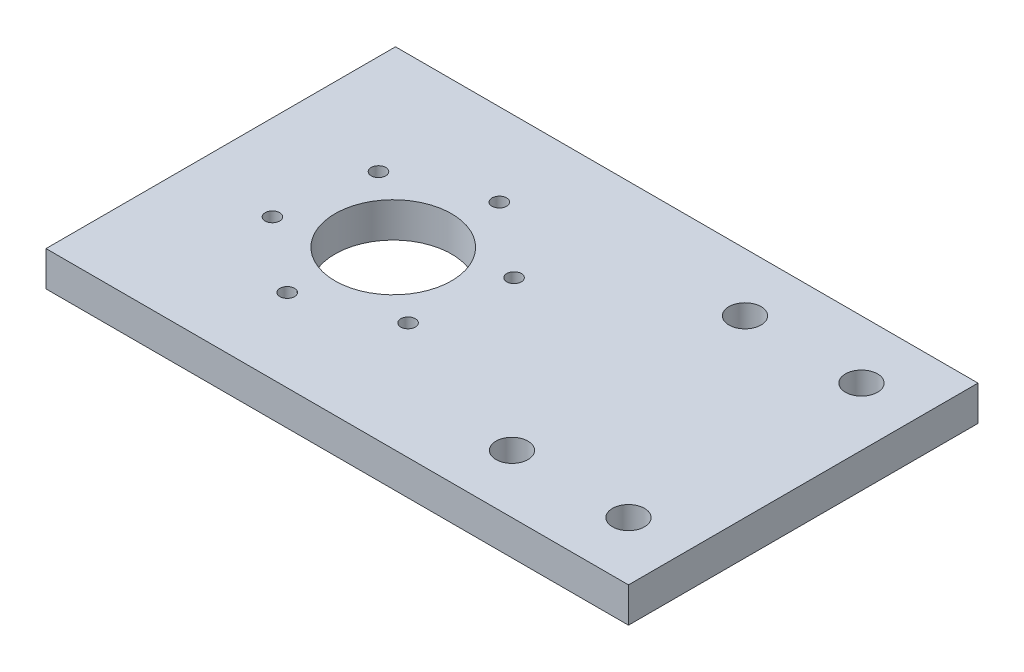
from build123d import *

# Parameters (mm, degrees)
SKETCH1_W           = 100
SKETCH1_H           = 60
BOSS_EXTRUDE1_DEPTH = 6
SKETCH2_R           = 10
SKETCH2_R_2         = 2.75
CUT_EXTRUDE1_DEPTH  = 6
SKETCH3_R           = 1.25
CUT_EXTRUDE2_DEPTH  = 7


with BuildPart() as part:
    # Sketch1 → Boss-Extrude1 (new body)
    with BuildSketch(Plane(origin=(0, 0, 0), x_dir=(1, 0, 0), z_dir=(0, 1, 0))):
        with Locations((50, 30)):
            Rectangle(SKETCH1_W, SKETCH1_H)
    extrude(amount=BOSS_EXTRUDE1_DEPTH)

    # Sketch2 → Cut-Extrude1 (cut)
    with BuildSketch(Plane(origin=(0, 6, 0), x_dir=(1, 0, 0), z_dir=(0, 1, 0))):
        with Locations((29.615341175, 30)):
            Circle(SKETCH2_R)
        with Locations((70, 50)):
            Circle(SKETCH2_R_2)
        with Locations((90, 50)):
            Circle(SKETCH2_R_2)
        with Locations((70, 10)):
            Circle(SKETCH2_R_2)
        with Locations((90, 10)):
            Circle(SKETCH2_R_2)
    extrude(amount=-CUT_EXTRUDE1_DEPTH, mode=Mode.SUBTRACT)

    # Sketch3 → Cut-Extrude2 (cut, through all)
    with BuildSketch(Plane(origin=(0, 6, 0), x_dir=(1, 0, 0), z_dir=(0, 1, 0))):
        with Locations((31.998383025, 45.821539481)):
            Circle(SKETCH3_R)
        with Locations((44.508717217, 35.846994961)):
            Circle(SKETCH3_R)
        with Locations((42.125675368, 20.02545548)):
            Circle(SKETCH3_R)
        with Locations((27.232299326, 14.178460519)):
            Circle(SKETCH3_R)
        with Locations((14.721965133, 24.153005039)):
            Circle(SKETCH3_R)
        with Locations((17.105006983, 39.97454452)):
            Circle(SKETCH3_R)
    extrude(amount=-CUT_EXTRUDE2_DEPTH, mode=Mode.SUBTRACT)


solid = part.part
